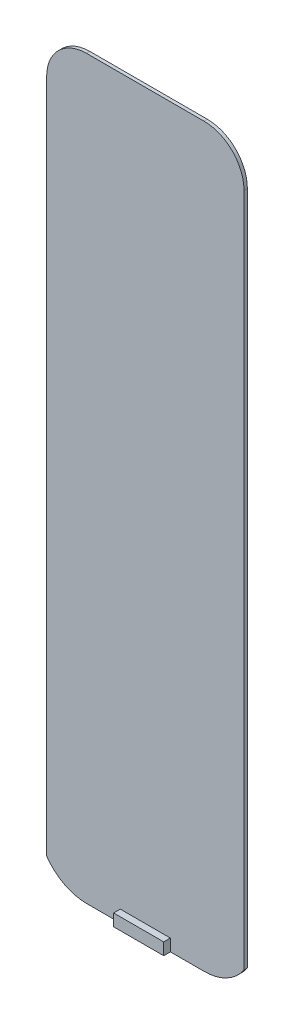
from build123d import *

# Parameters (mm, degrees)
EXTRUDE_1_DEPTH = 0.5
SKETCH_2_W      = 15
SKETCH_2_H      = 2
EXTRUDE_2_DEPTH = 3.6


with BuildPart() as part:
    # 草圖1 → 填料-伸長1 (new body, symmetric)
    with BuildSketch(Plane.XY):
        with BuildLine():
            Line((-17.6, 110.46), (17.6, 110.46))
            ThreePointArc((17.6, 110.46), (26.056997103, 106.956997103), (29.56, 98.5))
            Line((29.56, 98.5), (29.56, -103.764581662))
            ThreePointArc((29.56, -103.764581662), (24.409428177, -108.417234577), (17.675642482, -110.1))
            Line((17.675642482, -110.1), (-17.524357518, -110.1))
            ThreePointArc((-17.524357518, -110.1), (-24.32498645, -108.419421277), (-29.56, -103.764581662))
            Line((-29.56, -103.764581662), (-29.56, 98.5))
            ThreePointArc((-29.56, 98.5), (-26.056997103, 106.956997103), (-17.6, 110.46))
        make_face()
    extrude(amount=EXTRUDE_1_DEPTH, both=True)

    # 草圖2 → 填料-伸長2 (add)
    with BuildSketch(Plane.XZ.offset(110.1)):
        with Locations((0, -1.5)):
            Rectangle(SKETCH_2_W, SKETCH_2_H)
        with Locations((0, 1.5)):
            Rectangle(SKETCH_2_W, SKETCH_2_H)
    extrude(amount=-EXTRUDE_2_DEPTH)


solid = part.part
